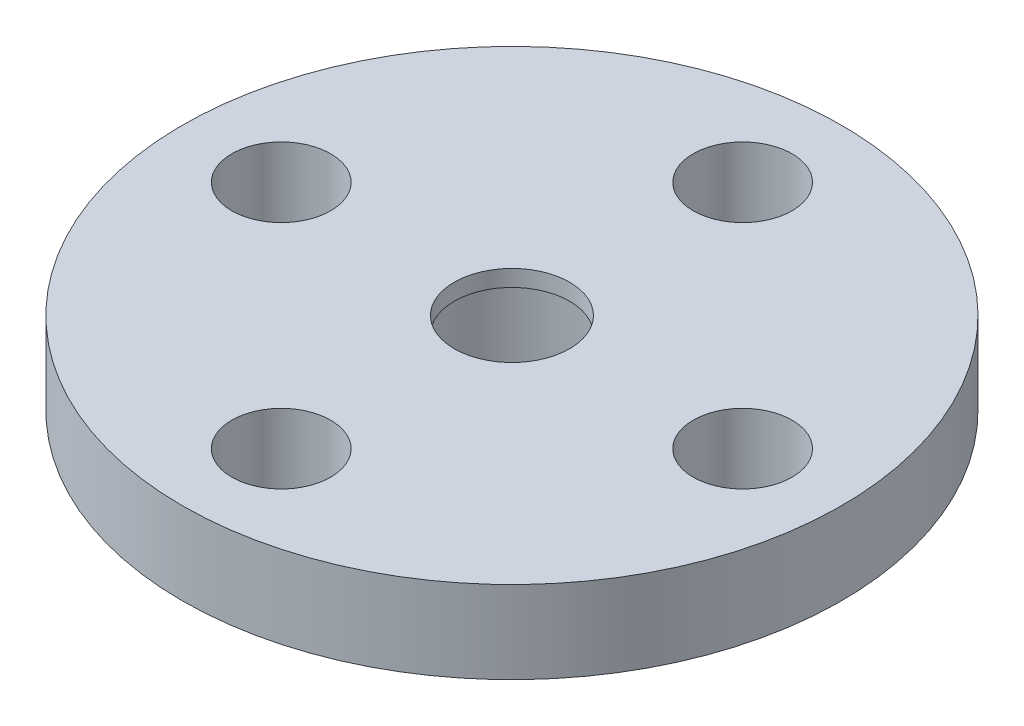
from build123d import *

# Parameters (mm, degrees)
SKETCH1_R           = 10
BOSS_EXTRUDE1_DEPTH = 2.5
SKETCH2_R           = 4.5
SKETCH2_R_2         = 3
BOSS_EXTRUDE2_DEPTH = 2
SKETCH3_R           = 1.5
SKETCH3_R_2         = 1.75
CUT_EXTRUDE1_DEPTH  = 15.84082208
CUT_EXTRUDE2_START  = -2
SKETCH2_2_R         = 3
CUT_EXTRUDE2_DEPTH  = 2


with BuildPart() as part:
    # Sketch1 → Boss-Extrude1 (new body)
    with BuildSketch(Plane(origin=(0, 0, 0), x_dir=(1, 0, 0), z_dir=(0, 1, 0))):
        Circle(SKETCH1_R)
    extrude(amount=BOSS_EXTRUDE1_DEPTH)

    # Sketch2 → Boss-Extrude2 (add)
    with BuildSketch(Plane.XZ):
        Circle(SKETCH2_R)
        Circle(SKETCH2_R_2, mode=Mode.SUBTRACT)
    extrude(amount=BOSS_EXTRUDE2_DEPTH)

    # Sketch3 → Cut-Extrude1 (cut, through all)
    with BuildSketch(Plane(origin=(0, 2.5, 0), x_dir=(1, 0, 0), z_dir=(0, 1, 0))):
        with Locations((0, 7)):
            Circle(SKETCH3_R)
        with Locations((7, 0)):
            Circle(SKETCH3_R)
        with Locations((0, -7)):
            Circle(SKETCH3_R)
        with Locations((-7, 0)):
            Circle(SKETCH3_R)
        Circle(SKETCH3_R_2)
    extrude(amount=-CUT_EXTRUDE1_DEPTH, mode=Mode.SUBTRACT)

    # Sketch2_2 → Cut-Extrude2 (cut)
    with BuildSketch(Plane.XZ.offset(CUT_EXTRUDE2_START)):
        Circle(SKETCH2_2_R)
    extrude(amount=CUT_EXTRUDE2_DEPTH, mode=Mode.SUBTRACT)


solid = part.part
